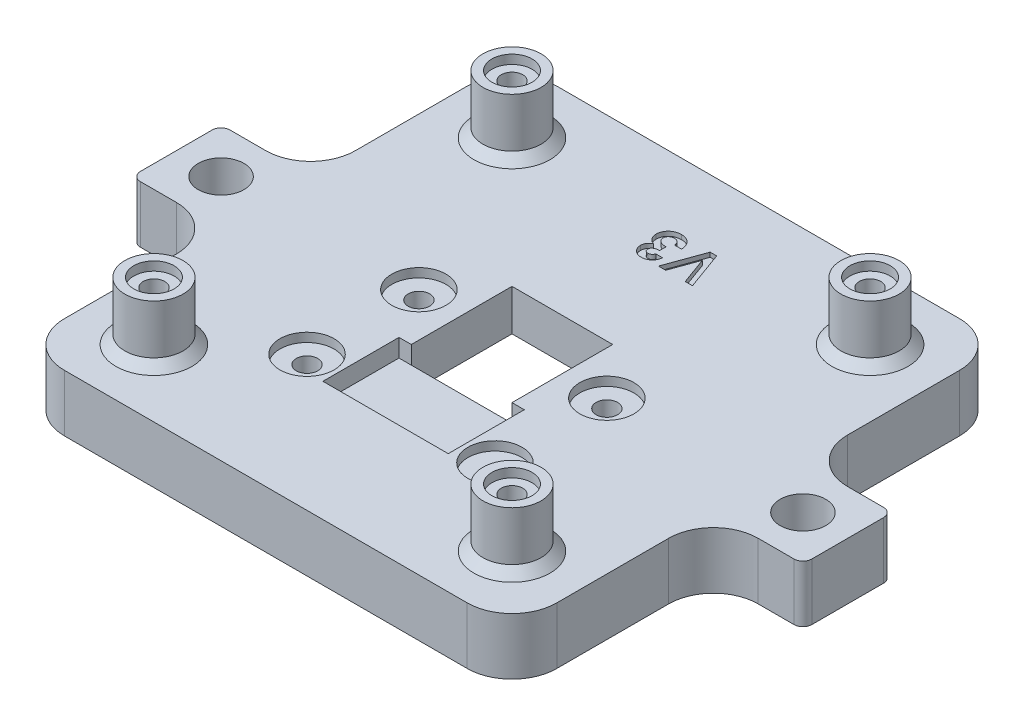
from build123d import *

# Parameters (mm, degrees)
SKETCH1_W                      = 55
SKETCH1_H                      = 55
BOSS_EXTRUDE1_DEPTH            = 6.35
SKETCH2_W                      = 11.25
SKETCH2_H                      = 11.25
CUT_EXTRUDE1_DEPTH             = 40.405868852
SKETCH3_W                      = 14
SKETCH3_H                      = 8.5
CUT_EXTRUDE2_DEPTH             = 2
CBORE_FOR_M2_SHCS2_D           = 2.4
CBORE_FOR_M2_SHCS2_CBORE_D     = 4.4
CBORE_FOR_M2_SHCS2_CBORE_DEPTH = 2
SKETCH6_R                      = 3.25
BOSS_EXTRUDE2_DEPTH            = 6.5
CBORE_FOR_M2_SHCS1_D           = 2.4
CBORE_FOR_M2_SHCS1_CBORE_D     = 4.4
CBORE_FOR_M2_SHCS1_CBORE_DEPTH = 2
SKETCH13_R                     = 3.025
CUT_EXTRUDE4_DEPTH             = 1
CHAMFER1_SIZE                  = 1.75
SKETCH16_W                     = 10
SKETCH16_H                     = 10
BOSS_EXTRUDE3_DEPTH            = 6.35
SKETCH17_R                     = 2.55
CUT_EXTRUDE6_DEPTH             = 49.245440199
FILLET1_R                      = 5
FILLET2_R                      = 1
SKETCH18_R                     = 2.25
CUT_EXTRUDE7_DEPTH             = 1
CUT_EXTRUDE8_DEPTH             = 0.5
CHAMFER2_SIZE                  = 1


with BuildPart() as part:
    # Sketch1 → Boss-Extrude1 (new body)
    with BuildSketch(Plane(origin=(0, 0, 0), x_dir=(1, 0, 0), z_dir=(0, 1, 0))):
        Rectangle(SKETCH1_W, SKETCH1_H)
    extrude(amount=BOSS_EXTRUDE1_DEPTH)

    # Sketch2 → Cut-Extrude1 (cut, through all)
    with BuildSketch(Plane(origin=(0, 6.35, 0), x_dir=(1, 0, 0), z_dir=(0, 1, 0))):
        Rectangle(SKETCH2_W, SKETCH2_H)
    extrude(amount=-CUT_EXTRUDE1_DEPTH, mode=Mode.SUBTRACT)

    # Sketch3 → Cut-Extrude2 (cut)
    with BuildSketch(Plane(origin=(0, 6.35, 0), x_dir=(1, 0, 0), z_dir=(0, 1, 0))):
        with Locations((0, -9.875)):
            Rectangle(SKETCH3_W, SKETCH3_H)
    extrude(amount=-CUT_EXTRUDE2_DEPTH, mode=Mode.SUBTRACT)

    # CBORE for M2 SHCS2 (through all)
    with Locations(Plane.XZ):
        with Locations((10.5, -0.1), (10.5, 12.4), (-10.5, 12.4), (-10.5, -0.1)):
            CounterBoreHole(CBORE_FOR_M2_SHCS2_D / 2, CBORE_FOR_M2_SHCS2_CBORE_D / 2, CBORE_FOR_M2_SHCS2_CBORE_DEPTH)

    # Sketch6 → Boss-Extrude2 (add)
    with BuildSketch(Plane(origin=(0, 6.35, 0), x_dir=(1, 0, 0), z_dir=(0, 1, 0))):
        with Locations(Location((-20, 20, 0), (0, 0, 90))):
            Circle(SKETCH6_R)
        with Locations(Location((20, 20, 0), (0, 0, 90))):
            Circle(SKETCH6_R)
        with Locations(Location((20, -20, 0), (0, 0, 90))):
            Circle(SKETCH6_R)
        with Locations(Location((-20, -20, 0), (0, 0, 90))):
            Circle(SKETCH6_R)
    extrude(amount=BOSS_EXTRUDE2_DEPTH)

    # CBORE for M2 SHCS1 (through all)
    with Locations(Plane.XZ):
        with Locations((-20, -20), (-20, 20), (20, 20), (20, -20)):
            CounterBoreHole(CBORE_FOR_M2_SHCS1_D / 2, CBORE_FOR_M2_SHCS1_CBORE_D / 2, CBORE_FOR_M2_SHCS1_CBORE_DEPTH)

    # Sketch13 → Cut-Extrude4 (cut)
    with BuildSketch(Plane(origin=(0, 6.35, 0), x_dir=(1, 0, 0), z_dir=(0, 1, 0))):
        with Locations(Location((-10.5, -12.4, 0), (0, 0, 270))):
            Circle(SKETCH13_R)
        with Locations(Location((-10.5, 0.1, 0), (0, 0, 270))):
            Circle(SKETCH13_R)
        with Locations(Location((10.5, -12.4, 0), (0, 0, 90))):
            Circle(SKETCH13_R)
        with Locations(Location((10.5, 0.1, 0), (0, 0, 90))):
            Circle(SKETCH13_R)
    extrude(amount=-CUT_EXTRUDE4_DEPTH, mode=Mode.SUBTRACT)

    # Chamfer1
    chamfer1_edges = [part.edges().sort_by_distance(p)[0] for p in [
        (5.625, 0, 0),
        (0, 0, 5.625),
        (-5.625, 0, 0),
        (0, 0, -5.625),
    ]]
    chamfer(chamfer1_edges, length=CHAMFER1_SIZE)

    # Sketch16 → Boss-Extrude3 (add)
    with BuildSketch(Plane.XZ):
        with Locations((32.5, 0)):
            Rectangle(SKETCH16_W, SKETCH16_H)
        with Locations((-32.5, 0)):
            Rectangle(SKETCH16_W, SKETCH16_H)
    extrude(amount=-BOSS_EXTRUDE3_DEPTH)

    # Sketch17 → Cut-Extrude6 (cut, through all)
    with BuildSketch(Plane.XZ):
        with Locations(Location((32.5, 0, 0), (0, 0, 270))):
            Circle(SKETCH17_R)
        with Locations(Location((-32.5, 0, 0), (0, 0, 270))):
            Circle(SKETCH17_R)
    extrude(amount=-CUT_EXTRUDE6_DEPTH, mode=Mode.SUBTRACT)

    # Fillet1
    fillet1_edges = [part.edges().sort_by_distance(p)[0] for p in [
        (27.5, 3.175, 5),
        (27.5, 3.175, -5),
        (-27.5, 3.175, -5),
        (-27.5, 3.175, 5),
        (27.5, 3.175, 27.5),
        (-27.5, 3.175, 27.5),
        (-27.5, 3.175, -27.5),
        (27.5, 3.175, -27.5),
    ]]
    fillet(fillet1_edges, radius=FILLET1_R)

    # Fillet2
    fillet2_edges = [part.edges().sort_by_distance(p)[0] for p in [
        (37.5, 3.175, -5),
        (37.5, 3.175, 5),
        (-37.5, 3.175, 5),
        (-37.5, 3.175, -5),
    ]]
    fillet(fillet2_edges, radius=FILLET2_R)

    # Sketch18 → Cut-Extrude7 (cut)
    with BuildSketch(Plane(origin=(0, 12.85, 0), x_dir=(1, 0, 0), z_dir=(0, 1, 0))):
        with Locations(Location((-20, 20, 0), (0, 0, 270))):
            Circle(SKETCH18_R)
        with Locations(Location((-20, -20, 0), (0, 0, 270))):
            Circle(SKETCH18_R)
        with Locations(Location((20, 20, 0), (0, 0, 270))):
            Circle(SKETCH18_R)
        with Locations(Location((20, -20, 0), (0, 0, 270))):
            Circle(SKETCH18_R)
    extrude(amount=-CUT_EXTRUDE7_DEPTH, mode=Mode.SUBTRACT)

    # Sketch19 → Cut-Extrude8 (cut)
    with BuildSketch(Plane(origin=(0, 6.35, 0), x_dir=(1, 0, 0), z_dir=(0, 1, 0))):
        with BuildLine():
            Line((-0.732692308, 16.797863248), (0.027136752, 16.797863248))
            add(Edge.make_bspline(
                [(0.027136752, 16.797863248), (0.021805536, 16.759873792), (0.011392352, 16.685670983), (-0.014206117, 16.577986818), (-0.043809195, 16.47558712), (-0.081667344, 16.379021437), (-0.125367748, 16.288393868), (-0.17632835, 16.203623313), (-0.232184544, 16.123493245), (-0.275916453, 16.075473774), (-0.29765625, 16.051602564)],
                knots=[0, 0, 0, 0, 1.1115466, 2.171125598, 3.205689823, 4.19946166, 5.17440286, 6.118867946, 7.064860634, 8, 8, 8, 8], degree=3))
            add(Edge.make_bspline(
                [(-0.29765625, 16.051602564), (-0.328935693, 16.02005754), (-0.390584188, 15.957885612), (-0.493606054, 15.878250239), (-0.601591994, 15.80933124), (-0.716707716, 15.75469176), (-0.837161931, 15.71046743), (-0.963912533, 15.680761848), (-1.096441572, 15.661051932), (-1.18687597, 15.659110436), (-1.233026175, 15.658119658)],
                knots=[0, 0, 0, 0, 1.01925491, 2.00884431, 2.983262333, 3.955970413, 4.92937149, 5.924503185, 6.940838805, 8, 8, 8, 8], degree=3))
            add(Edge.make_bspline(
                [(-1.233026175, 15.658119658), (-1.274056082, 15.659088294), (-1.354712612, 15.660992436), (-1.473257416, 15.67627786), (-1.586279966, 15.703086791), (-1.694974944, 15.738138867), (-1.797743799, 15.785833074), (-1.896854742, 15.841195897), (-1.989538608, 15.9091007), (-2.07601226, 15.985826293), (-2.155454802, 16.068812534), (-2.224252391, 16.157518), (-2.283398914, 16.249573165), (-2.332127825, 16.345742833), (-2.369593735, 16.446189734), (-2.395596188, 16.5503336), (-2.412615425, 16.65794463), (-2.414310986, 16.731086398), (-2.41517094, 16.768182425)],
                knots=[0, 0, 0, 0, 1.091422571, 2.145516843, 3.172569842, 4.178562979, 5.178154469, 6.181868002, 7.194278174, 8.227918432, 9.254613415, 10.245994977, 11.209837596, 12.161663635, 13.10878368, 14.055455738, 15.013766427, 16, 16, 16, 16], degree=3))
            add(Edge.make_bspline(
                [(-2.41517094, 16.768182425), (-2.413372285, 16.81411461), (-2.409820439, 16.904817962), (-2.38173055, 17.037307866), (-2.336574452, 17.163704133), (-2.272369171, 17.282509148), (-2.191741367, 17.393599151), (-2.092866643, 17.493094266), (-1.978504203, 17.582535352), (-1.892653183, 17.630601606), (-1.848691239, 17.655215011)],
                knots=[0, 0, 0, 0, 0.992776698, 1.96045919, 2.915875678, 3.886951799, 4.871409521, 5.874469288, 6.911574252, 8, 8, 8, 8], degree=3))
            add(Edge.make_bspline(
                [(-1.848691239, 17.655215011), (-1.878867171, 17.665120771), (-1.938161524, 17.684585147), (-2.022424323, 17.722943692), (-2.102614567, 17.764774149), (-2.176898332, 17.813606734), (-2.247312675, 17.866056742), (-2.311629781, 17.924944254), (-2.37151512, 17.988757721), (-2.425487204, 18.058175998), (-2.473740749, 18.132044911), (-2.516266126, 18.209036775), (-2.551952911, 18.289432982), (-2.58190465, 18.372642731), (-2.604756998, 18.459484943), (-2.620834453, 18.549665321), (-2.630130643, 18.642966578), (-2.63154819, 18.70617856), (-2.632264957, 18.738141026)],
                knots=[0, 0, 0, 0, 1.059375415, 2.081625174, 3.086260357, 4.075579879, 5.045586876, 6.014170127, 6.982201689, 7.963705737, 8.945119069, 9.924852636, 10.896327119, 11.878239286, 12.873838556, 13.889973282, 14.933087432, 16, 16, 16, 16], degree=3))
            add(Edge.make_bspline(
                [(-2.632264957, 18.738141026), (-2.630936316, 18.785133481), (-2.628315393, 18.877832409), (-2.608309131, 19.013923816), (-2.576175726, 19.144373346), (-2.531029156, 19.269345422), (-2.471918129, 19.388464738), (-2.400524109, 19.502532309), (-2.31597485, 19.610651827), (-2.219552277, 19.711865376), (-2.113368236, 19.804750526), (-1.998981878, 19.886735911), (-1.876321383, 19.954339922), (-1.748312602, 20.012118132), (-1.612082421, 20.054999985), (-1.469390207, 20.086402585), (-1.31919476, 20.105508971), (-1.216687474, 20.107519975), (-1.164336271, 20.108547009)],
                knots=[0, 0, 0, 0, 1.005301618, 1.9830924, 2.936709333, 3.876255674, 4.820386332, 5.77704884, 6.75110905, 7.752325838, 8.764085485, 9.766124222, 10.757295257, 11.756573224, 12.766631673, 13.80722022, 14.880131728, 16, 16, 16, 16], degree=3))
            add(Edge.make_bspline(
                [(-1.164336271, 20.108547009), (-1.114811664, 20.107466929), (-1.017972849, 20.105354976), (-0.876328549, 20.087066338), (-0.741698684, 20.057585678), (-0.613787959, 20.01595954), (-0.493140948, 19.962328804), (-0.37905476, 19.897595615), (-0.272774864, 19.819776541), (-0.173811963, 19.730707618), (-0.08300504, 19.632153954), (-0.003863256, 19.523312227), (0.065010957, 19.406560724), (0.124072157, 19.281648367), (0.170217951, 19.147460602), (0.206916477, 19.005195778), (0.232465997, 18.854238731), (0.240257972, 18.750386002), (0.244230769, 18.697435897)],
                knots=[0, 0, 0, 0, 1.066693477, 2.085777942, 3.071407889, 4.032495163, 4.978645371, 5.911608997, 6.853298848, 7.810770565, 8.776420673, 9.735131334, 10.704462168, 11.693492242, 12.70668109, 13.756973703, 14.856375978, 16, 16, 16, 16], degree=3))
            Line((0.244230769, 18.697435897), (-0.515598291, 18.697435897))
            add(Edge.make_bspline(
                [(-0.515598291, 18.697435897), (-0.520414187, 18.724059847), (-0.529794409, 18.775916971), (-0.548073412, 18.851001941), (-0.571956152, 18.920282732), (-0.59926121, 18.984268334), (-0.629450157, 19.043615409), (-0.665520715, 19.096736913), (-0.704196357, 19.145720523), (-0.762334657, 19.202023882), (-0.843450906, 19.261069861), (-0.953277538, 19.313363683), (-1.076006595, 19.343105149), (-1.161632367, 19.34680541), (-1.205889423, 19.348717949)],
                knots=[0, 0, 0, 0, 0.928450228, 1.808400301, 2.64896863, 3.43999153, 4.194978884, 4.9294959, 5.640047715, 6.332896648, 7.70085756, 9.063442004, 10.482192841, 12, 12, 12, 12], degree=3))
            add(Edge.make_bspline(
                [(-1.205889423, 19.348717949), (-1.229377393, 19.348313773), (-1.275385073, 19.347522084), (-1.342974601, 19.338796884), (-1.407320705, 19.324322879), (-1.469095523, 19.304894812), (-1.527456459, 19.279275344), (-1.583149624, 19.248808711), (-1.635184039, 19.211771037), (-1.68372361, 19.170005748), (-1.72765233, 19.124014829), (-1.767383443, 19.075974278), (-1.799271554, 19.023921117), (-1.825741286, 18.969913895), (-1.847575631, 18.913966566), (-1.861274449, 18.854806162), (-1.871530519, 18.793618456), (-1.872131094, 18.751755254), (-1.872435897, 18.730508814)],
                knots=[0, 0, 0, 0, 1.110416125, 2.175056767, 3.216269732, 4.226816172, 5.232753079, 6.226173397, 7.223992381, 8.247806573, 9.250094092, 10.229378924, 11.190237183, 12.128982156, 13.072570213, 14.022671385, 14.996464856, 16, 16, 16, 16], degree=3))
            add(Edge.make_bspline(
                [(-1.872435897, 18.730508814), (-1.871661975, 18.707264309), (-1.870130531, 18.661267863), (-1.856653897, 18.593862274), (-1.836481364, 18.528772446), (-1.807469517, 18.466535418), (-1.769506224, 18.407517213), (-1.723346752, 18.351229041), (-1.668573533, 18.298119047), (-1.607020772, 18.246640454), (-1.536204925, 18.201576338), (-1.458985647, 18.160079026), (-1.373460576, 18.127036937), (-1.281681472, 18.09753144), (-1.181922669, 18.075979284), (-1.074800627, 18.060330841), (-0.960489025, 18.048682846), (-0.881692515, 18.047011761), (-0.841239316, 18.046153846)],
                knots=[0, 0, 0, 0, 0.809868251, 1.602574917, 2.388262527, 3.182133002, 3.988875265, 4.829537611, 5.714850619, 6.646378958, 7.622533229, 8.636771727, 9.698525113, 10.814716514, 11.996253919, 13.252421425, 14.589425562, 16, 16, 16, 16], degree=3))
            Line((-0.841239316, 18.046153846), (-0.841239316, 17.340598291))
            add(Edge.make_bspline(
                [(-0.841239316, 17.340598291), (-0.891611005, 17.336321), (-0.98584646, 17.328319035), (-1.116576315, 17.309407598), (-1.22721906, 17.284681731), (-1.318964046, 17.253007884), (-1.396284489, 17.215836844), (-1.462110375, 17.17173689), (-1.520711802, 17.122906525), (-1.568555682, 17.066819695), (-1.60721795, 17.007613922), (-1.634593679, 16.945452253), (-1.652766004, 16.88171659), (-1.654488421, 16.838121284), (-1.65534188, 16.816519765)],
                knots=[0, 0, 0, 0, 1.700278244, 3.18088388, 4.44026007, 5.507838349, 6.439172496, 7.317391478, 8.167251366, 8.996486918, 9.787781501, 10.536992524, 11.275078289, 12, 12, 12, 12], degree=3))
            add(Edge.make_bspline(
                [(-1.65534188, 16.816519765), (-1.65390338, 16.788940974), (-1.651095731, 16.735113012), (-1.628276577, 16.658263918), (-1.591201885, 16.588623282), (-1.539001694, 16.528591961), (-1.475133579, 16.479026786), (-1.400730169, 16.442900323), (-1.317052957, 16.421291186), (-1.258315762, 16.419088107), (-1.227938034, 16.417948718)],
                knots=[0, 0, 0, 0, 1.008776249, 1.968917671, 2.909425455, 3.878736958, 4.86052431, 5.85160606, 6.888892716, 8, 8, 8, 8], degree=3))
            add(Edge.make_bspline(
                [(-1.227938034, 16.417948718), (-1.200405382, 16.419300824), (-1.145772166, 16.421983815), (-1.065914301, 16.442098077), (-0.990163296, 16.47561565), (-0.920461846, 16.522683838), (-0.856981376, 16.578630086), (-0.803754292, 16.644353519), (-0.760424152, 16.717283454), (-0.741972495, 16.770898018), (-0.732692308, 16.797863248)],
                knots=[0, 0, 0, 0, 0.988439209, 1.961366134, 2.938893463, 3.950078543, 4.971412263, 5.967491143, 6.977757845, 8, 8, 8, 8], degree=3))
        make_face()
        Polygon((4.396153846, 15.766666667), (3.584595353, 15.766666667), (2.496581197, 18.773758013), (1.40602297, 15.766666667), (0.597008547, 15.766666667), (2.13193109, 20), (2.863775374, 20), align=None)
    extrude(amount=-CUT_EXTRUDE8_DEPTH, mode=Mode.SUBTRACT)

    # Chamfer2
    chamfer2_edges = [part.edges().sort_by_distance(p)[0] for p in [
        (-20, 6.35, -16.75),
        (20, 6.35, -16.75),
        (20, 6.35, 23.25),
        (-20, 6.35, 23.25),
    ]]
    chamfer(chamfer2_edges, length=CHAMFER2_SIZE)


solid = part.part
